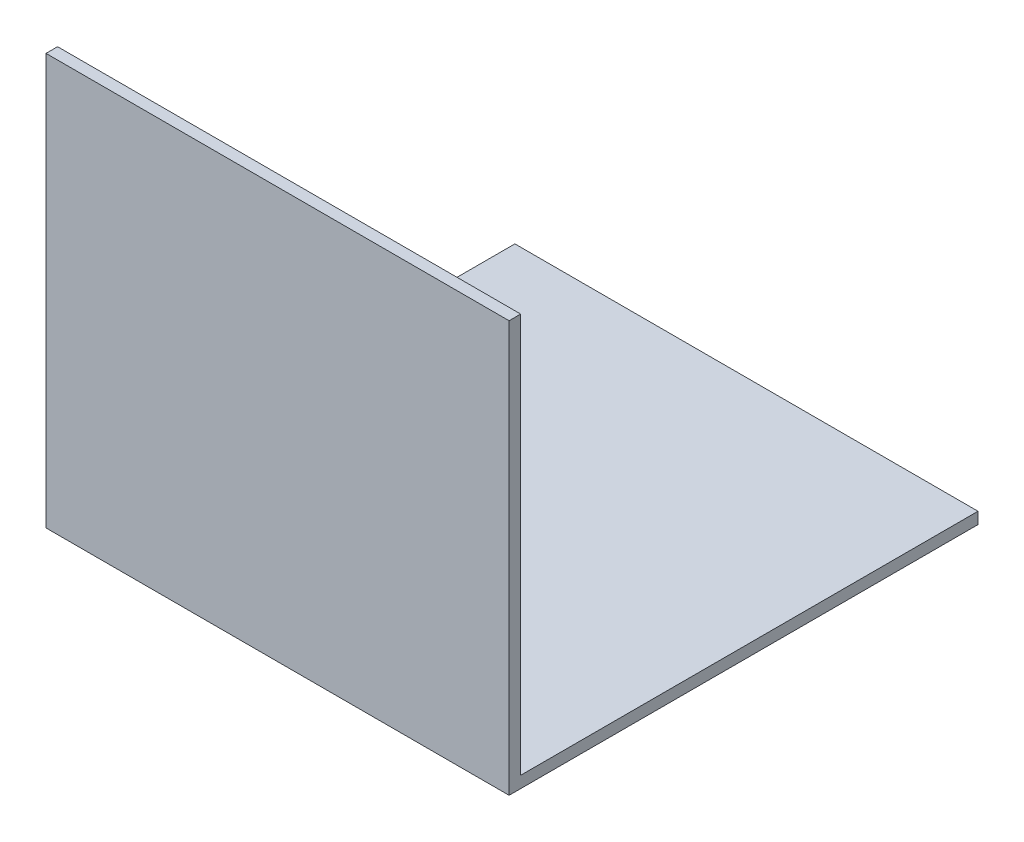
from build123d import *

# Parameters (mm, degrees)
EXTRUDE_THIN1_DEPTH = 800


with BuildPart() as part:
    # Sketch1 → Extrude-Thin1 (new body)
    with BuildSketch(Plane(origin=(0, 0, 0), x_dir=(0, 0, -1), z_dir=(1, 0, 0))):
        Polygon((-10, 700), (-10, -10), (800, -10), (800, 10), (10, 10), (10, 700), align=None)
    extrude(amount=EXTRUDE_THIN1_DEPTH)


solid = part.part
